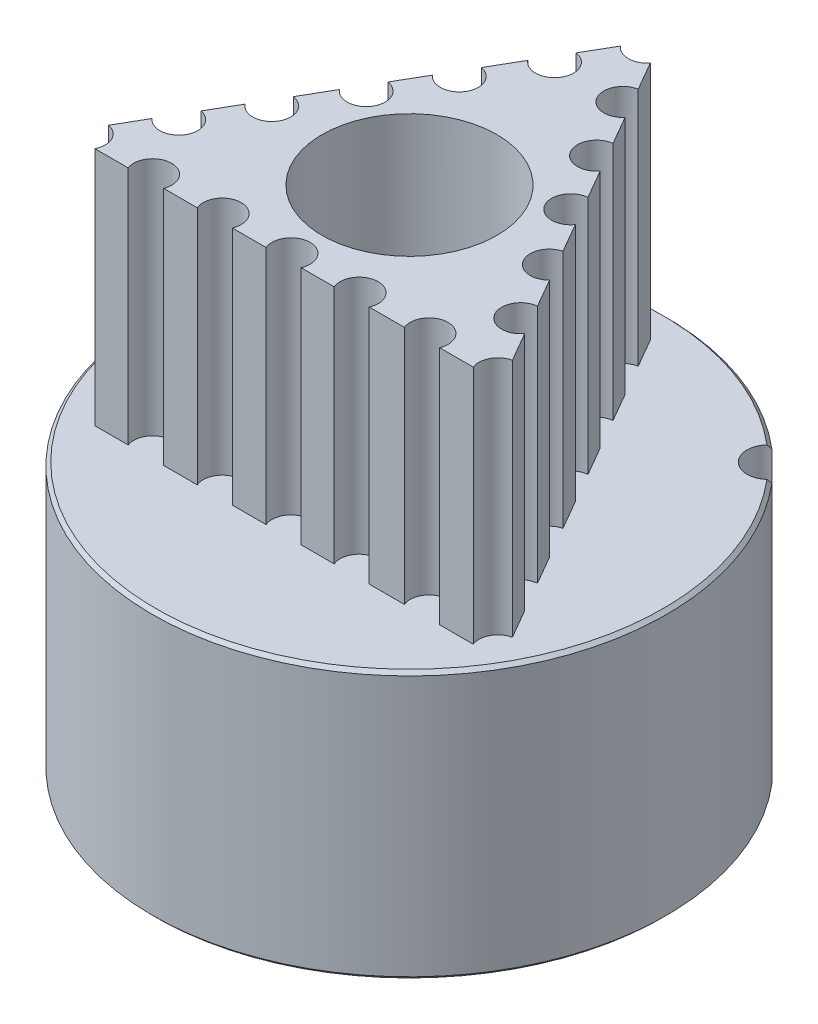
from build123d import *

# Parameters (mm, degrees)
P_IDAT_START            = 7.8
SKICA1_R                = 2.5
P_IDAT_VYSUNUT_M1_DEPTH = 7
SKICA2_R                = 3.5
SKICA2_R_2              = 2.5
P_IDAT_VYSUNUT_M2_DEPTH = 7.8
SKICA3_R                = 3.5
SKICA3_R_2              = 2.5
P_IDAT_VYSUNUT_M3_DEPTH = 1.2
SKICA5_R                = 7.5
SKICA5_R_2              = 3.5
P_IDAT_VYSUNUT_M4_DEPTH = 1.2
SKICA6_R                = 7.5
SKICA6_R_2              = 3.5
P_IDAT_VYSUNUT_M5_DEPTH = 7.8
ZKOSEN_1_SIZE           = 0.1
ZKOSEN_2_SIZE           = 0.1
ZKOSEN_3_SIZE           = 0.1
SKETCH8_OUTSIDE_W       = 22.314
SKETCH8_OUTSIDE_H       = 22.314
SKETCH8_OUTSIDE_R       = 6.65
CUT_EXTRUDE2_DEPTH      = 5
SKETCH32_R              = 6.65
CUT_EXTRUDE3_DEPTH      = 7
BOSS_EXTRUDE1_DEPTH     = 7
SKETCH34_R              = 2.55
CUT_EXTRUDE4_DEPTH      = 30
SKETCH20_R              = 1.5
CUT_EXTRUDE5_DEPTH      = 8
SKETCH19_R              = 1.5
CUT_EXTRUDE6_DEPTH      = 8
SKETCH30_R              = 0.617994848
CUT_EXTRUDE7_DEPTH      = 8
SKETCH36_R              = 10.482134683
CUT_EXTRUDE8_DEPTH      = 10


with BuildPart() as part:
    # Skica1 → Přidat vysunutím1 (new body)
    with BuildSketch(Plane(origin=(0, 0, 0), x_dir=(1, 0, 0), z_dir=(0, 1, 0)).offset(P_IDAT_START)):
        with BuildLine():
            ThreePointArc((-5.730143195, 1.098270155), (-5.09645097, 1.530497044), (-5.387174672, 2.240331989))
            ThreePointArc((-5.387174672, 2.240331989), (-5.468060657, 2.292707421), (-5.540463547, 2.356296335))
            ThreePointArc((-5.540463547, 2.356296335), (-5.573874331, 2.399596558), (-5.596043873, 2.44959357))
            ThreePointArc((-5.596043873, 2.44959357), (-5.50369925, 2.650567912), (-5.404139771, 2.848067596))
            ThreePointArc((-5.404139771, 2.848067596), (-5.351227535, 2.86190541), (-5.296542742, 2.862779021))
            ThreePointArc((-5.296542742, 2.862779021), (-5.201685094, 2.845815675), (-5.110305882, 2.815228615))
            ThreePointArc((-5.110305882, 2.815228615), (-4.374063308, 3.030479148), (-4.431206919, 3.795410862))
            ThreePointArc((-4.431206919, 3.795410862), (-4.491949163, 3.870218002), (-4.541158349, 3.953068377))
            ThreePointArc((-4.541158349, 3.953068377), (-4.559553388, 4.004573836), (-4.565187949, 4.058974585))
            ThreePointArc((-4.565187949, 4.058974585), (-4.415258506, 4.221576484), (-4.259541056, 4.378644275))
            ThreePointArc((-4.259541056, 4.378644275), (-4.204942409, 4.375454038), (-4.15266412, 4.359386362))
            ThreePointArc((-4.15266412, 4.359386362), (-4.067691098, 4.313940635), (-3.990236225, 4.256612884))
            ThreePointArc((-3.990236225, 4.256612884), (-3.223511854, 4.233816838), (-3.041481758, 4.978968476))
            ThreePointArc((-3.041481758, 4.978968476), (-3.076134388, 5.06888468), (-3.097332931, 5.162886543))
            ThreePointArc((-3.097332931, 5.162886543), (-3.09891159, 5.217555525), (-3.08745962, 5.271034888))
            ThreePointArc((-3.08745962, 5.271034888), (-2.894621497, 5.379347737), (-2.697988784, 5.480608745))
            ThreePointArc((-2.697988784, 5.480608745), (-2.647048223, 5.460702739), (-2.6022938, 5.429266591))
            ThreePointArc((-2.6022938, 5.429266591), (-2.535523156, 5.359787029), (-2.479574443, 5.281330225))
            ThreePointArc((-2.479574443, 5.281330225), (-1.7574206, 5.022719037), (-1.354035171, 5.675149965))
            ThreePointArc((-1.354035171, 5.675149965), (-1.359206146, 5.771373608), (-1.350318985, 5.867325402))
            ThreePointArc((-1.350318985, 5.867325402), (-1.334926735, 5.919806527), (-1.307509232, 5.967129569))
            ThreePointArc((-1.307509232, 5.967129569), (-1.090638767, 6.010550954), (-0.872338572, 6.046093045))
            ThreePointArc((-0.872338572, 6.046093045), (-0.830042514, 6.01141981), (-0.797192832, 5.967692379))
            ThreePointArc((-0.797192832, 5.967692379), (-0.755160541, 5.880980125), (-0.726194639, 5.789074167))
            ThreePointArc((-0.726194639, 5.789074167), (-0.119300773, 5.319962501), (0.465953812, 5.815808234))
            ThreePointArc((0.465953812, 5.815808234), (0.490770664, 5.908920276), (0.528873591, 5.997429571))
            ThreePointArc((0.528873591, 5.997429571), (0.55973005, 6.04258562), (0.600429269, 6.079120034))
            ThreePointArc((0.600429269, 6.079120034), (0.820103284, 6.053399565), (1.038702217, 6.019743632))
            ThreePointArc((1.038702217, 6.019743632), (1.06821354, 5.973697225), (1.085942924, 5.921958857))
            ThreePointArc((1.085942924, 5.921958857), (1.099122448, 5.826501911), (1.098270155, 5.730143195))
            ThreePointArc((1.098270155, 5.730143195), (1.530497044, 5.09645097), (2.240331989, 5.387174672))
            ThreePointArc((2.240331989, 5.387174672), (2.292707421, 5.468060657), (2.356296335, 5.540463547))
            ThreePointArc((2.356296335, 5.540463547), (2.399596558, 5.573874331), (2.44959357, 5.596043873))
            ThreePointArc((2.44959357, 5.596043873), (2.650567912, 5.50369925), (2.848067596, 5.404139771))
            ThreePointArc((2.848067596, 5.404139771), (2.86190541, 5.351227535), (2.862779021, 5.296542742))
            ThreePointArc((2.862779021, 5.296542742), (2.845815675, 5.201685094), (2.815228615, 5.110305882))
            ThreePointArc((2.815228615, 5.110305882), (3.030479148, 4.374063308), (3.795410862, 4.431206919))
            ThreePointArc((3.795410862, 4.431206919), (3.870218002, 4.491949163), (3.953068377, 4.541158349))
            ThreePointArc((3.953068377, 4.541158349), (4.004573836, 4.559553388), (4.058974585, 4.565187949))
            ThreePointArc((4.058974585, 4.565187949), (4.221576484, 4.415258506), (4.378644275, 4.259541056))
            ThreePointArc((4.378644275, 4.259541056), (4.375454038, 4.204942409), (4.359386362, 4.15266412))
            ThreePointArc((4.359386362, 4.15266412), (4.313940635, 4.067691098), (4.256612884, 3.990236225))
            ThreePointArc((4.256612884, 3.990236225), (4.233816838, 3.223511854), (4.978968476, 3.041481758))
            ThreePointArc((4.978968476, 3.041481758), (5.06888468, 3.076134388), (5.162886543, 3.097332931))
            ThreePointArc((5.162886543, 3.097332931), (5.217555525, 3.09891159), (5.271034888, 3.08745962))
            ThreePointArc((5.271034888, 3.08745962), (5.379347737, 2.894621497), (5.480608745, 2.697988784))
            ThreePointArc((5.480608745, 2.697988784), (5.460702739, 2.647048223), (5.429266591, 2.6022938))
            ThreePointArc((5.429266591, 2.6022938), (5.359787029, 2.535523156), (5.281330225, 2.479574443))
            ThreePointArc((5.281330225, 2.479574443), (5.022719037, 1.7574206), (5.675149965, 1.354035171))
            ThreePointArc((5.675149965, 1.354035171), (5.771373608, 1.359206146), (5.867325402, 1.350318985))
            ThreePointArc((5.867325402, 1.350318985), (5.919806527, 1.334926735), (5.967129569, 1.307509232))
            ThreePointArc((5.967129569, 1.307509232), (6.010550954, 1.090638767), (6.046093045, 0.872338572))
            ThreePointArc((6.046093045, 0.872338572), (6.01141981, 0.830042514), (5.967692379, 0.797192832))
            ThreePointArc((5.967692379, 0.797192832), (5.880980125, 0.755160541), (5.789074167, 0.726194639))
            ThreePointArc((5.789074167, 0.726194639), (5.319962501, 0.119300773), (5.815808234, -0.465953812))
            ThreePointArc((5.815808234, -0.465953812), (5.908920276, -0.490770664), (5.997429571, -0.528873591))
            ThreePointArc((5.997429571, -0.528873591), (6.04258562, -0.55973005), (6.079120034, -0.600429269))
            ThreePointArc((6.079120034, -0.600429269), (6.053399565, -0.820103284), (6.019743632, -1.038702217))
            ThreePointArc((6.019743632, -1.038702217), (5.973697225, -1.06821354), (5.921958857, -1.085942924))
            ThreePointArc((5.921958857, -1.085942924), (5.826501911, -1.099122448), (5.730143195, -1.098270155))
            ThreePointArc((5.730143195, -1.098270155), (5.09645097, -1.530497044), (5.387174672, -2.240331989))
            ThreePointArc((5.387174672, -2.240331989), (5.468060657, -2.292707421), (5.540463547, -2.356296335))
            ThreePointArc((5.540463547, -2.356296335), (5.573874331, -2.399596558), (5.596043873, -2.44959357))
            ThreePointArc((5.596043873, -2.44959357), (5.50369925, -2.650567911), (5.404139771, -2.848067596))
            ThreePointArc((5.404139771, -2.848067596), (5.351227535, -2.86190541), (5.296542742, -2.862779021))
            ThreePointArc((5.296542742, -2.862779021), (5.201685094, -2.845815675), (5.110305882, -2.815228615))
            ThreePointArc((5.110305882, -2.815228615), (4.374063308, -3.030479148), (4.431206919, -3.795410862))
            ThreePointArc((4.431206919, -3.795410862), (4.491949163, -3.870218002), (4.541158349, -3.953068377))
            ThreePointArc((4.541158349, -3.953068377), (4.559553388, -4.004573836), (4.565187949, -4.058974585))
            ThreePointArc((4.565187949, -4.058974585), (4.415258506, -4.221576484), (4.259541056, -4.378644275))
            ThreePointArc((4.259541056, -4.378644275), (4.204942409, -4.375454038), (4.15266412, -4.359386362))
            ThreePointArc((4.15266412, -4.359386362), (4.067691098, -4.313940635), (3.990236225, -4.256612884))
            ThreePointArc((3.990236225, -4.256612884), (3.223511854, -4.233816838), (3.041481758, -4.978968476))
            ThreePointArc((3.041481758, -4.978968476), (3.076134388, -5.06888468), (3.097332931, -5.162886543))
            ThreePointArc((3.097332931, -5.162886543), (3.09891159, -5.217555525), (3.08745962, -5.271034888))
            ThreePointArc((3.08745962, -5.271034888), (2.894621497, -5.379347737), (2.697988784, -5.480608745))
            ThreePointArc((2.697988784, -5.480608745), (2.647048223, -5.460702739), (2.6022938, -5.429266591))
            ThreePointArc((2.6022938, -5.429266591), (2.535523156, -5.359787029), (2.479574443, -5.281330225))
            ThreePointArc((2.479574443, -5.281330225), (1.7574206, -5.022719037), (1.354035171, -5.675149965))
            ThreePointArc((1.354035171, -5.675149965), (1.359206146, -5.771373608), (1.350318985, -5.867325402))
            ThreePointArc((1.350318985, -5.867325402), (1.334926735, -5.919806527), (1.307509232, -5.967129569))
            ThreePointArc((1.307509232, -5.967129569), (1.090638767, -6.010550954), (0.872338572, -6.046093045))
            ThreePointArc((0.872338572, -6.046093045), (0.830042514, -6.01141981), (0.797192832, -5.967692379))
            ThreePointArc((0.797192832, -5.967692379), (0.755160541, -5.880980125), (0.726194639, -5.789074167))
            ThreePointArc((0.726194639, -5.789074167), (0.119300773, -5.319962501), (-0.465953812, -5.815808234))
            ThreePointArc((-0.465953812, -5.815808234), (-0.490770664, -5.908920276), (-0.528873591, -5.997429571))
            ThreePointArc((-0.528873591, -5.997429571), (-0.55973005, -6.04258562), (-0.600429269, -6.079120034))
            ThreePointArc((-0.600429269, -6.079120034), (-0.820103284, -6.053399565), (-1.038702217, -6.019743632))
            ThreePointArc((-1.038702217, -6.019743632), (-1.06821354, -5.973697225), (-1.085942924, -5.921958857))
            ThreePointArc((-1.085942924, -5.921958857), (-1.099122448, -5.826501911), (-1.098270155, -5.730143195))
            ThreePointArc((-1.098270155, -5.730143195), (-1.530497044, -5.09645097), (-2.240331989, -5.387174672))
            ThreePointArc((-2.240331989, -5.387174672), (-2.292707421, -5.468060657), (-2.356296335, -5.540463547))
            ThreePointArc((-2.356296335, -5.540463547), (-2.399596558, -5.573874331), (-2.44959357, -5.596043873))
            ThreePointArc((-2.44959357, -5.596043873), (-2.650567912, -5.50369925), (-2.848067596, -5.404139771))
            ThreePointArc((-2.848067596, -5.404139771), (-2.86190541, -5.351227535), (-2.862779021, -5.296542742))
            ThreePointArc((-2.862779021, -5.296542742), (-2.845815675, -5.201685094), (-2.815228615, -5.110305882))
            ThreePointArc((-2.815228615, -5.110305882), (-3.030479148, -4.374063308), (-3.795410862, -4.431206919))
            ThreePointArc((-3.795410862, -4.431206919), (-3.870218002, -4.491949163), (-3.953068377, -4.541158349))
            ThreePointArc((-3.953068377, -4.541158349), (-4.004573836, -4.559553388), (-4.058974585, -4.565187949))
            ThreePointArc((-4.058974585, -4.565187949), (-4.221576484, -4.415258506), (-4.378644275, -4.259541056))
            ThreePointArc((-4.378644275, -4.259541056), (-4.375454038, -4.204942409), (-4.359386362, -4.15266412))
            ThreePointArc((-4.359386362, -4.15266412), (-4.313940635, -4.067691098), (-4.256612884, -3.990236225))
            ThreePointArc((-4.256612884, -3.990236225), (-4.233816838, -3.223511854), (-4.978968476, -3.041481758))
            ThreePointArc((-4.978968476, -3.041481758), (-5.06888468, -3.076134388), (-5.162886543, -3.097332931))
            ThreePointArc((-5.162886543, -3.097332931), (-5.217555525, -3.09891159), (-5.271034888, -3.08745962))
            ThreePointArc((-5.271034888, -3.08745962), (-5.379347737, -2.894621497), (-5.480608745, -2.697988784))
            ThreePointArc((-5.480608745, -2.697988784), (-5.460702739, -2.647048223), (-5.429266591, -2.6022938))
            ThreePointArc((-5.429266591, -2.6022938), (-5.359787029, -2.535523156), (-5.281330225, -2.479574443))
            ThreePointArc((-5.281330225, -2.479574443), (-5.022719037, -1.7574206), (-5.675149965, -1.354035171))
            ThreePointArc((-5.675149965, -1.354035171), (-5.771373608, -1.359206146), (-5.867325402, -1.350318985))
            ThreePointArc((-5.867325402, -1.350318985), (-5.919806527, -1.334926735), (-5.967129569, -1.307509232))
            ThreePointArc((-5.967129569, -1.307509232), (-6.010550954, -1.090638767), (-6.046093045, -0.872338572))
            ThreePointArc((-6.046093045, -0.872338572), (-6.01141981, -0.830042514), (-5.967692379, -0.797192832))
            ThreePointArc((-5.967692379, -0.797192832), (-5.880980125, -0.755160541), (-5.789074167, -0.726194639))
            ThreePointArc((-5.789074167, -0.726194639), (-5.319962501, -0.119300773), (-5.815808234, 0.465953812))
            ThreePointArc((-5.815808234, 0.465953812), (-5.908920276, 0.490770664), (-5.997429571, 0.528873591))
            ThreePointArc((-5.997429571, 0.528873591), (-6.04258562, 0.55973005), (-6.079120034, 0.600429269))
            ThreePointArc((-6.079120034, 0.600429269), (-6.053399565, 0.820103284), (-6.019743632, 1.038702217))
            ThreePointArc((-6.019743632, 1.038702217), (-5.973697225, 1.06821354), (-5.921958857, 1.085942924))
            ThreePointArc((-5.921958857, 1.085942924), (-5.826501911, 1.099122448), (-5.730143195, 1.098270155))
        make_face()
        Circle(SKICA1_R, mode=Mode.SUBTRACT)
    extrude(amount=P_IDAT_VYSUNUT_M1_DEPTH)

    # Skica2 → Přidat vysunutím2 (add)
    with BuildSketch(Plane.XZ.offset(-7.8)):
        Circle(SKICA2_R)
        Circle(SKICA2_R_2, mode=Mode.SUBTRACT)
    extrude(amount=P_IDAT_VYSUNUT_M2_DEPTH)

    # Skica3 → Přidat vysunutím3 (add)
    with BuildSketch(Plane(origin=(0, 14.8, 0), x_dir=(1, 0, 0), z_dir=(0, 1, 0))):
        Circle(SKICA3_R)
        Circle(SKICA3_R_2, mode=Mode.SUBTRACT)
    extrude(amount=P_IDAT_VYSUNUT_M3_DEPTH)

    # Zkosení2
    zkosen_2_edges = [part.edges().sort_by_distance(p)[0] for p in [
        (-2.5, 0, 0),
        (-2.5, 16, 0),
    ]]
    chamfer(zkosen_2_edges, length=ZKOSEN_2_SIZE)

    # Sketch32 → Cut-Extrude3 (cut)
    with BuildSketch(Plane(origin=(0, 7.8, 0), x_dir=(1, 0, 0), z_dir=(0, 1, 0))):
        Circle(SKETCH32_R)
    extrude(amount=CUT_EXTRUDE3_DEPTH, mode=Mode.SUBTRACT)



with BuildPart() as body_2:
    # Skica5 → Přidat vysunutím4 (new body)
    with BuildSketch(Plane(origin=(0, 16, 0), x_dir=(1, 0, 0), z_dir=(0, 1, 0))):
        Circle(SKICA5_R)
        Circle(SKICA5_R_2, mode=Mode.SUBTRACT)
    extrude(amount=-P_IDAT_VYSUNUT_M4_DEPTH)

    # Zkosení1
    zkosen_1_edges = [body_2.edges().sort_by_distance(p)[0] for p in [
        (-7.5, 16, 0),
        (-7.5, 14.8, 0),
    ]]
    chamfer(zkosen_1_edges, length=ZKOSEN_1_SIZE)

    # Sketch8 outside → Cut-Extrude2 (cut)
    with BuildSketch(Plane(origin=(0, 16, 0), x_dir=(1, 0, 0), z_dir=(0, 1, 0))):
        Rectangle(SKETCH8_OUTSIDE_W, SKETCH8_OUTSIDE_H)
        Circle(SKETCH8_OUTSIDE_R, mode=Mode.SUBTRACT)
    extrude(amount=-CUT_EXTRUDE2_DEPTH, mode=Mode.SUBTRACT)


with BuildPart() as body_3:
    # Skica6 → Přidat vysunutím5 (new body)
    with BuildSketch(Plane.XZ):
        Circle(SKICA6_R)
        Circle(SKICA6_R_2, mode=Mode.SUBTRACT)
    extrude(amount=-P_IDAT_VYSUNUT_M5_DEPTH)

    # Zkosení3
    zkosen_3_edges = [body_3.edges().sort_by_distance(p)[0] for p in [
        (-7.5, 0, 0),
        (-7.5, 7.8, 0),
    ]]
    chamfer(zkosen_3_edges, length=ZKOSEN_3_SIZE)


with BuildPart() as part_1:
    add(part.part)

    add(body_2.part)  # Boss-Extrude1 merges body 2

    add(body_3.part)  # Boss-Extrude1 merges body 3
    # Sketch25 → Boss-Extrude1 (add)
    with BuildSketch(Plane(origin=(0, 7.8, 0), x_dir=(1, 0, 0), z_dir=(0, 1, 0))):
        with BuildLine():
            Line((-0.717938034, 6.096494849), (-0.907057907, 5.768929619))
            ThreePointArc((-0.907057907, 5.768929619), (-0.50810169, 4.942474166), (-1.423311217, 4.874752658))
            Line((-1.423311217, 4.874752658), (-1.918483232, 4.017089569))
            ThreePointArc((-1.918483232, 4.017089569), (-1.536908146, 3.193503192), (-2.440942413, 3.112163722))
            Line((-2.440942413, 3.112163722), (-2.91615597, 2.289069697))
            ThreePointArc((-2.91615597, 2.289069697), (-2.524743358, 1.463789867), (-3.435162962, 1.390123218))
            Line((-3.435162962, 1.390123218), (-3.927672168, 0.53707225))
            ThreePointArc((-3.927672168, 0.53707225), (-3.52415558, -0.290042476), (-4.442216238, -0.354144223))
            Line((-4.442216238, -0.354144223), (-4.911986074, -1.167809446))
            ThreePointArc((-4.911986074, -1.167809446), (-4.535840997, -1.990382794), (-5.436282951, -2.075918275))
            Line((-5.436282951, -2.075918275), (-5.898945462, -2.877273251))
            ThreePointArc((-5.898945462, -2.877273251), (-5.507068696, -3.176777484), (-5.508386199, -3.67))
            Line((-5.508386199, -3.67), (-4.536814361, -3.67))
            ThreePointArc((-4.536814361, -3.67), (-4.017748656, -2.91854188), (-3.49868295, -3.67))
            Line((-3.49868295, -3.67), (-2.520776964, -3.67))
            ThreePointArc((-2.520776964, -3.67), (-2.009979522, -2.897949376), (-1.499182081, -3.67))
            Line((-1.499182081, -3.67), (-0.513007831, -3.67))
            ThreePointArc((-0.513007831, -3.67), (-0.002210389, -2.897949376), (0.508587053, -3.67))
            Line((0.508587053, -3.67), (1.474168799, -3.67))
            ThreePointArc((1.474168799, -3.67), (1.98496624, -2.897949376), (2.495763682, -3.67))
            Line((2.495763682, -3.67), (3.518869287, -3.67))
            ThreePointArc((3.518869287, -3.67), (4.033920381, -2.908245628), (4.548971475, -3.67))
            Line((4.548971475, -3.67), (5.530558251, -3.67))
            ThreePointArc((5.530558251, -3.67), (5.556358411, -3.205925047), (5.92604395, -2.92420921))
            Line((5.92604395, -2.92420921), (5.4337836, -2.071589272))
            ThreePointArc((5.4337836, -2.071589272), (4.505290561, -2.021283953), (4.925971396, -1.192032735))
            Line((4.925971396, -1.192032735), (4.445945351, -0.360603235))
            ThreePointArc((4.445945351, -0.360603235), (3.569336636, -0.24921119), (3.911172652, 0.565650249))
            Line((3.911172652, 0.565650249), (3.418477875, 1.419022635))
            ThreePointArc((3.418477875, 1.419022635), (2.483630084, 1.460464645), (2.915164146, 2.290787587))
            Line((2.915164146, 2.290787587), (2.427366725, 3.135677503))
            ThreePointArc((2.427366725, 3.135677503), (1.503804697, 3.192615402), (1.916276044, 4.02091253))
            Line((1.916276044, 4.02091253), (1.436397938, 4.852085792))
            ThreePointArc((1.436397938, 4.852085792), (0.532106306, 4.93312138), (0.914073244, 5.7567787))
            Line((0.914073244, 5.7567787), (0.432060736, 6.591648854))
            ThreePointArc((0.432060736, 6.591648854), (0, 6.385), (-0.432060736, 6.591648854))
            Line((-0.432060736, 6.591648854), (-0.717938034, 6.096494849))
        make_face()
    extrude(amount=BOSS_EXTRUDE1_DEPTH)

    # Sketch34 → Cut-Extrude4 (cut)
    with BuildSketch(Plane(origin=(0, 16, 0), x_dir=(1, 0, 0), z_dir=(0, 1, 0))):
        Circle(SKETCH34_R)
    extrude(amount=-CUT_EXTRUDE4_DEPTH, mode=Mode.SUBTRACT)

    # Sketch20 → Cut-Extrude5 (cut)
    with BuildSketch(Plane.ZY.offset(7.5)):
        with Locations((0, 3.9)):
            Circle(SKETCH20_R)
    extrude(amount=-CUT_EXTRUDE5_DEPTH, mode=Mode.SUBTRACT)

    # Sketch19 → Cut-Extrude6 (cut)
    with BuildSketch(Plane(origin=(0, 0, -7.5), x_dir=(-1, 0, 0), z_dir=(0, 0, -1))):
        with Locations((0, 3.9)):
            Circle(SKETCH19_R)
    extrude(amount=-CUT_EXTRUDE6_DEPTH, mode=Mode.SUBTRACT)

    # Sketch30 → Cut-Extrude7 (cut)
    with BuildSketch(Plane.XZ):
        with Locations((5.232590181, -5.232590181)):
            Circle(SKETCH30_R)
    extrude(amount=-CUT_EXTRUDE7_DEPTH, mode=Mode.SUBTRACT)

    # Sketch36 → Cut-Extrude8 (cut)
    with BuildSketch(Plane.XZ.offset(-14.8)):
        Circle(SKETCH36_R)
    extrude(amount=-CUT_EXTRUDE8_DEPTH, mode=Mode.SUBTRACT)


solid = part_1.part
